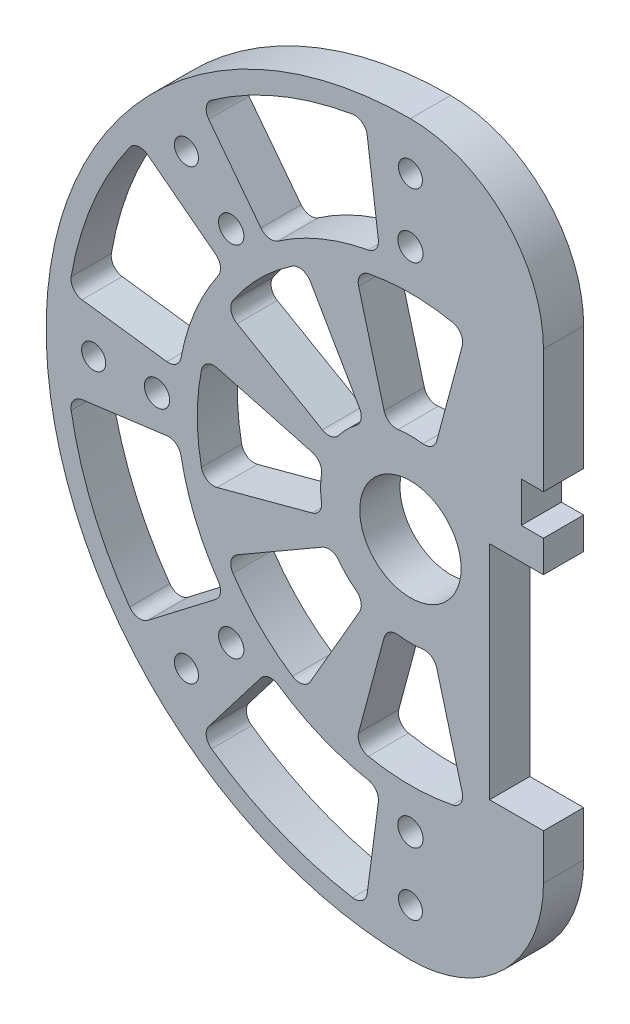
from build123d import *

# Parameters (mm, degrees)
SKETCH1_R                = 57.5
SKETCH1_R_2              = 1.89865
SKETCH1_R_3              = 1.9939
SKETCH1_R_4              = 8
BOSS_EXTRUDE1_DEPTH      = 6.35
CUT_EXTRUDE1_DEPTH       = 82.564836173
SKETCH3_W                = 6.35
SKETCH3_H                = 80
CUT_EXTRUDE3_DEPTH       = 82.564836173
CUT_EXTRUDE4_DEPTH       = 82.564836173
CUT_EXTRUDE6_DEPTH       = 82.564836173
FILLET1_R                = 2
CIRPATTERN1_COUNT        = 8
FILLET1_OF_CIRPATTERN1_R = 2
CUT_EXTRUDE7_DEPTH       = 10
FILLET2_R                = 2
CIRPATTERN2_COUNT        = 8
FILLET2_OF_CIRPATTERN2_R = 2


with BuildPart() as part:
    # Sketch1 → Boss-Extrude1 (new body)
    with BuildSketch(Plane.XY):
        Circle(SKETCH1_R)
        with Locations((45.315389352, 21.130913087)):
            Circle(SKETCH1_R_2, mode=Mode.SUBTRACT)
        with Locations((46.467376211, -18.460307366)):
            Circle(SKETCH1_R_3, mode=Mode.SUBTRACT)
        Circle(SKETCH1_R_4, mode=Mode.SUBTRACT)
        with Locations((49.978847504, 1.454235937)):
            Circle(SKETCH1_R_3, mode=Mode.SUBTRACT)
        with Locations((0, -40)):
            Circle(SKETCH1_R_3, mode=Mode.SUBTRACT)
        with Locations((0, -50)):
            Circle(SKETCH1_R_2, mode=Mode.SUBTRACT)
        with Locations((-28.284271247, -28.284271247)):
            Circle(SKETCH1_R_3, mode=Mode.SUBTRACT)
        with Locations((-35.355339059, -35.355339059)):
            Circle(SKETCH1_R_2, mode=Mode.SUBTRACT)
        with Locations((-40, 0)):
            Circle(SKETCH1_R_3, mode=Mode.SUBTRACT)
        with Locations((-50, 0)):
            Circle(SKETCH1_R_2, mode=Mode.SUBTRACT)
        with Locations((-28.284271247, 28.284271247)):
            Circle(SKETCH1_R_3, mode=Mode.SUBTRACT)
        with Locations((-35.355339059, 35.355339059)):
            Circle(SKETCH1_R_2, mode=Mode.SUBTRACT)
        with Locations((0, 40)):
            Circle(SKETCH1_R_3, mode=Mode.SUBTRACT)
        with Locations((0, 50)):
            Circle(SKETCH1_R_2, mode=Mode.SUBTRACT)
        with Locations((35.355339059, -35.355339059)):
            Circle(SKETCH1_R_2, mode=Mode.SUBTRACT)
    extrude(amount=BOSS_EXTRUDE1_DEPTH)

    # Sketch2 → Cut-Extrude1 (cut, through all)
    with BuildSketch(Plane.XY):
        Polygon((12.5, -29.35), (41, -29.35), (41, 10.65), (44.5, 10.65), (44.5, 17), (41, 17), (41, 32), (21, 32), (21, 17), (17.5, 17), (17.5, 10.65), (21, 10.65), (21, 5.65), (12.5, 5.65), align=None)
    extrude(amount=CUT_EXTRUDE1_DEPTH, mode=Mode.SUBTRACT)

    # Sketch3 → Cut-Extrude3 (cut, through all)
    with BuildSketch(Plane.XY.offset(6.35)):
        with Locations((31, 32)):
            Rectangle(SKETCH3_W, SKETCH3_H)
    extrude(amount=-CUT_EXTRUDE3_DEPTH, mode=Mode.SUBTRACT)

    # Sketch4 → Cut-Extrude4 (cut, through all)
    with BuildSketch(Plane.XY.offset(6.35)):
        with BuildLine():
            Line((21, -36.5), (21, -16.443021443))
            Line((21, -16.443021443), (24.175, -16.470277755))
            Line((24.175, -16.470277755), (24.175, -57.5))
            Line((24.175, -57.5), (0, -57.5))
            ThreePointArc((0, -57.5), (14.849242405, -51.349242405), (21, -36.5))
        make_face()
        with BuildLine():
            Line((0, 57.5), (24.175, 57.5))
            Line((24.175, 57.5), (24.175, 16.470277755))
            Line((24.175, 16.470277755), (21, 16.443021443))
            Line((21, 16.443021443), (21, 36.5))
            ThreePointArc((21, 36.5), (14.849242405, 51.349242405), (0, 57.5))
        make_face()
    extrude(amount=-CUT_EXTRUDE4_DEPTH, mode=Mode.SUBTRACT)


with BuildPart() as cut_extrude4_kept_piece:
    # of the separate pieces the step leaves, the one the design keeps (cut_extrude4_pieces_kept)
    add(part.part.solids().sort_by_distance((0, 57.5, 0))[0])

    # Sketch6 → Cut-Extrude6 (cut, through all)
    with BuildSketch(Plane.XY.offset(6.35)):
        with BuildLine():
            Line((-13.691998588, 3.668759964), (-32.503404055, 8.709260868))
            ThreePointArc((-32.503404055, 8.709260868), (-33.65, 0), (-32.503404055, -8.709260868))
            Line((-32.503404055, -8.709260868), (-13.691998588, -3.668759964))
            ThreePointArc((-13.691998588, -3.668759964), (-14.175, 0), (-13.691998588, 3.668759964))
        make_face()
    cut_extrude6 = extrude(amount=-CUT_EXTRUDE6_DEPTH, mode=Mode.SUBTRACT)

    # Fillet1
    fillet1_edges = [cut_extrude4_kept_piece.edges().sort_by_distance(p)[0] for p in [
        (-13.691998588, 3.668759964, 3.175),
        (-13.691998588, -3.668759964, 3.175),
        (-32.503404055, -8.709260868, 3.175),
        (-32.503404055, 8.709260868, 3.175),
    ]]
    fillet(fillet1_edges, radius=FILLET1_R)

    # CirPattern1: Cut-Extrude6 ×8 about axis, 3 skipped
    cirpattern1_axis = Axis((0, 0, 0), (0, 0, -1))
    add([cut_extrude6.rotate(cirpattern1_axis, i * 360 / CIRPATTERN1_COUNT) for i in range(1, CIRPATTERN1_COUNT) if i not in (3, 4, 5)], mode=Mode.SUBTRACT)

    # Fillet1 of CirPattern1
    fillet1_of_cirpattern1_edges = [cut_extrude4_kept_piece.edges().sort_by_distance(p)[0] for p in [
        (-7.0875, 12.275910099, 3.175),
        (-12.275910099, 7.0875, 3.175),
        (-29.141754837, 16.825, 3.175),
        (-16.825, 29.141754837, 3.175),
        (3.668759964, 13.691998588, 3.175),
        (-3.668759964, 13.691998588, 3.175),
        (-8.709260868, 32.503404055, 3.175),
        (8.709260868, 32.503404055, 3.175),
        (-3.668759964, -13.691998588, 3.175),
        (3.668759964, -13.691998588, 3.175),
        (8.709260868, -32.503404055, 3.175),
        (-8.709260868, -32.503404055, 3.175),
        (-12.275910099, -7.0875, 3.175),
        (-7.0875, -12.275910099, 3.175),
        (-16.825, -29.141754837, 3.175),
        (-29.141754837, -16.825, 3.175),
    ]]
    fillet(fillet1_of_cirpattern1_edges, radius=FILLET1_OF_CIRPATTERN1_R)

    # Sketch7 → Cut-Extrude7 (cut)
    with BuildSketch(Plane.XY.offset(6.35)):
        with BuildLine():
            Line((-43.098920211, 33.070964631), (-29.215236756, 22.417639623))
            ThreePointArc((-29.215236756, 22.417639623), (-34.021863785, 14.092317397), (-36.50995702, 4.806627029))
            Line((-36.50995702, 4.806627029), (-53.860242094, 7.090835392))
            ThreePointArc((-53.860242094, 7.090835392), (-50.189755604, 20.789277463), (-43.098920211, 33.070964631))
        make_face()
    cut_extrude7 = extrude(amount=-CUT_EXTRUDE7_DEPTH, mode=Mode.SUBTRACT)

    # Fillet2
    fillet2_edges = [cut_extrude4_kept_piece.edges().sort_by_distance(p)[0] for p in [
        (-29.215236756, 22.417639623, 3.175),
        (-36.50995702, 4.806627029, 3.175),
        (-53.860242094, 7.090835392, 3.175),
        (-43.098920211, 33.070964631, 3.175),
    ]]
    fillet(fillet2_edges, radius=FILLET2_R)

    # CirPattern2: Cut-Extrude7 ×8 about axis, 4 skipped
    cirpattern2_axis = Axis((0, 0, 0), (0, 0, -1))
    add([cut_extrude7.rotate(cirpattern2_axis, i * 360 / CIRPATTERN2_COUNT) for i in range(1, CIRPATTERN2_COUNT) if i not in (2, 3, 4, 5)], mode=Mode.SUBTRACT)

    # Fillet2 of CirPattern2
    fillet2_of_cirpattern2_edges = [cut_extrude4_kept_piece.edges().sort_by_distance(p)[0] for p in [
        (-4.806627029, 36.50995702, 3.175),
        (-22.417639623, 29.215236756, 3.175),
        (-33.070964631, 43.098920211, 3.175),
        (-7.090835392, 53.860242094, 3.175),
        (-22.417639623, -29.215236756, 3.175),
        (-4.806627029, -36.50995702, 3.175),
        (-7.090835392, -53.860242094, 3.175),
        (-33.070964631, -43.098920211, 3.175),
        (-36.50995702, -4.806627029, 3.175),
        (-29.215236756, -22.417639623, 3.175),
        (-43.098920211, -33.070964631, 3.175),
        (-53.860242094, -7.090835392, 3.175),
    ]]
    fillet(fillet2_of_cirpattern2_edges, radius=FILLET2_OF_CIRPATTERN2_R)


solid = cut_extrude4_kept_piece.part
